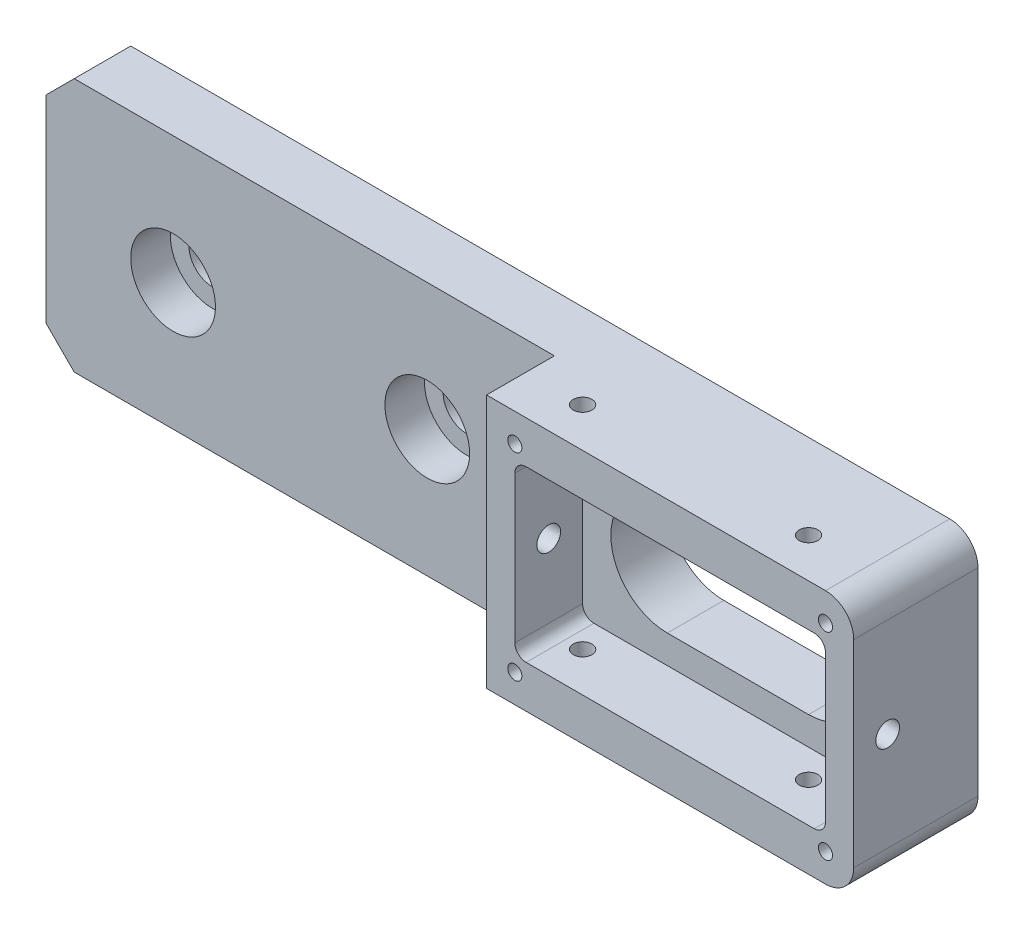
from build123d import *

# Parameters (mm, degrees)
SKETCH1_W                 = 155
SKETCH1_H                 = 45
BOSS_EXTRUDE1_DEPTH       = 10
SKETCH2_W                 = 65
SKETCH2_H                 = 45
BOSS_EXTRUDE2_DEPTH       = 12
CUT_EXTRUDE1_DEPTH        = 59
SKETCH4_W                 = 55
SKETCH4_H                 = 30
CUT_EXTRUDE2_DEPTH        = 12
M5_TAPPED_HOLE1_D         = 4.2
M3_TAPPED_HOLE1_D         = 2.5
M3_TAPPED_HOLE1_DEPTH     = 7.5
M3_TAPPED_HOLE1_TIP       = 0.751075774
HOLE_WIZARD_M4_1_D        = 3.3
CHAMFER1_SIZE             = 5
FILLET_1_R                = 5
FILLET_2_R                = 2
HOLE_WIZARD_1_D           = 8.4
HOLE_WIZARD_1_CBORE_D     = 15
HOLE_WIZARD_1_CBORE_DEPTH = 7


with BuildPart() as part:
    # Sketch1 → Boss-Extrude1 (new body)
    with BuildSketch(Plane.XY):
        with Locations((31.848694107, 0)):
            Rectangle(SKETCH1_W, SKETCH1_H)
    extrude(amount=BOSS_EXTRUDE1_DEPTH)

    # Sketch2 → Boss-Extrude2 (add)
    with BuildSketch(Plane.XY.offset(10)):
        with Locations((76.848694107, 0)):
            Rectangle(SKETCH2_W, SKETCH2_H)
    extrude(amount=BOSS_EXTRUDE2_DEPTH)

    # Sketch3 → Cut-Extrude1 (cut)
    with BuildSketch(Plane.XY.offset(22)):
        with BuildLine():
            Line((64.348694107, 10), (89.348694107, 10))
            ThreePointArc((89.348694107, 10), (99.348694107, 0), (89.348694107, -10))
            Line((89.348694107, -10), (64.348694107, -10))
            ThreePointArc((64.348694107, -10), (54.348694107, 0), (64.348694107, 10))
        make_face()
    extrude(amount=-CUT_EXTRUDE1_DEPTH, mode=Mode.SUBTRACT)

    # Sketch4 → Cut-Extrude2 (cut)
    with BuildSketch(Plane.XY.offset(22)):
        with Locations((76.848694107, 0)):
            Rectangle(SKETCH4_W, SKETCH4_H)
    extrude(amount=-CUT_EXTRUDE2_DEPTH, mode=Mode.SUBTRACT)

    # M5 Tapped Hole1 (through all)
    with Locations(Plane.ZY.offset(-44.348694107)):
        with Locations((16, 0)):
            Hole(M5_TAPPED_HOLE1_D / 2)

    # M3 Tapped Hole1
    with Locations(Plane.XY.offset(22)):
        with Locations((104.348694107, -17.5), (104.348694107, 17.5), (49.348694107, -17.5), (49.348694107, 17.5)):
            Hole(M3_TAPPED_HOLE1_D / 2, depth=M3_TAPPED_HOLE1_DEPTH)
            with Locations((0, 0, -(M3_TAPPED_HOLE1_DEPTH + M3_TAPPED_HOLE1_TIP / 2))):  # 118° drill point
                Cone(0, M3_TAPPED_HOLE1_D / 2, M3_TAPPED_HOLE1_TIP, mode=Mode.SUBTRACT)

    # M4 螺纹孔1 (through all)
    with Locations(Plane(origin=(0, -22.5, 0), x_dir=(-1, 0, 0), z_dir=(0, -1, 0))):
        with Locations((-94.348694107, -15), (-54.348694107, -15)):
            Hole(HOLE_WIZARD_M4_1_D / 2)

    # Chamfer1
    chamfer1_edges = [part.edges().sort_by_distance(p)[0] for p in [
        (-45.651305893, -22.5, 5),
        (-45.651305893, 22.5, 5),
    ]]
    chamfer(chamfer1_edges, length=CHAMFER1_SIZE)

    # 圆角1
    fillet_1_edges = [part.edges().sort_by_distance(p)[0] for p in [
        (109.348694107, 22.5, 11),
        (109.348694107, -22.5, 11),
    ]]
    fillet(fillet_1_edges, radius=FILLET_1_R)

    # 圆角2
    fillet_2_edges = [part.edges().sort_by_distance(p)[0] for p in [
        (49.348694107, -15, 16),
        (49.348694107, 15, 16),
        (104.348694107, 15, 16),
        (104.348694107, -15, 16),
    ]]
    fillet(fillet_2_edges, radius=FILLET_2_R)

    # 打孔尺寸(%根据)内六角圆柱头螺钉的类型1 (through all)
    with Locations(Plane.XY.offset(10)):
        with Locations((21.848694107, 0), (-23.151305893, 0)):
            CounterBoreHole(HOLE_WIZARD_1_D / 2, HOLE_WIZARD_1_CBORE_D / 2, HOLE_WIZARD_1_CBORE_DEPTH)


solid = part.part
